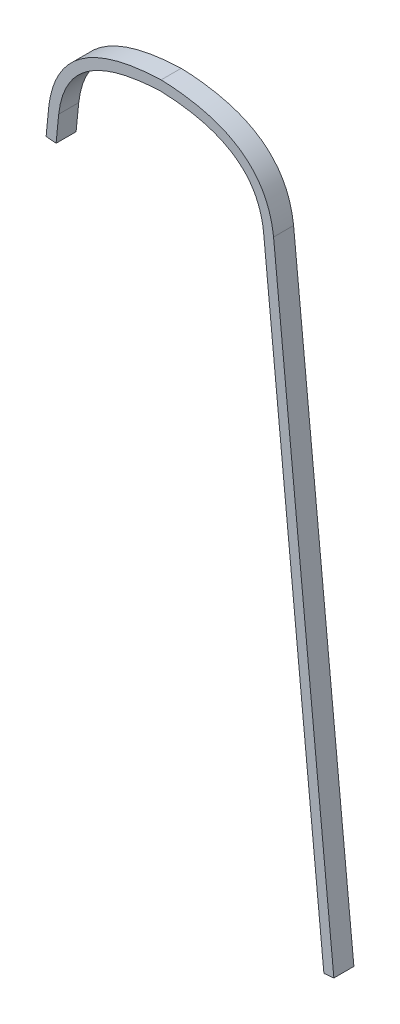
from build123d import *

# Parameters (mm, degrees)
BOSS_EXTRUDE1_DEPTH = 19.05


with BuildPart() as part:
    # Sketch1 → Boss-Extrude1 (new body)
    with BuildSketch(Plane.XY):
        with BuildLine():
            Line((154.716315659, 154.51789158), (97.403993572, 735.828587024))
            add(Edge.make_bspline(
                [(0, 803.26908628), (0.979817658, 803.233925105), (2.950075123, 803.151909058), (6.800362849, 802.946009068), (11.504912112, 802.608232022), (16.957304332, 802.075979486), (23.975792063, 801.198424891), (32.273128008, 799.790052384), (41.46699497, 797.614109593), (49.89784204, 794.967332344), (60.129456963, 790.832450746), (71.050790712, 784.572420078), (79.648241417, 776.932392043), (85.274313562, 769.943199813), (88.89525226, 764.228265264), (91.933130485, 758.00316425), (93.979934001, 752.359286407), (95.321414001, 747.554999291), (96.177362738, 743.805316844), (96.764020616, 740.553537606), (97.155379667, 737.881968465), (97.326205951, 736.51096636), (97.403993572, 735.828587024)],
                knots=[0.000508173, 0.000508173, 0.000508173, 0.000508173, 0.016098161, 0.031688149, 0.062868125, 0.094048101, 0.125228077, 0.187588029, 0.249947981, 0.312307933, 0.374667885, 0.499387789, 0.624107693, 0.686467645, 0.748827597, 0.811187549, 0.873547501, 0.904727477, 0.935907453, 0.967087429, 0.982677417, 0.998267405, 0.998267405, 0.998267405, 0.998267405], degree=3))
            add(Edge.make_bspline(
                [(-97.403993572, 735.828587024), (-97.326205951, 736.51096636), (-97.155379667, 737.881968465), (-96.764020616, 740.553537606), (-96.177362738, 743.805316844), (-95.321414001, 747.554999291), (-93.979934001, 752.359286407), (-91.933130485, 758.00316425), (-88.89525226, 764.228265264), (-85.274313562, 769.943199813), (-79.648241417, 776.932392043), (-71.050790712, 784.572420078), (-60.129456963, 790.832450746), (-49.89784204, 794.967332344), (-41.46699497, 797.614109593), (-32.273128008, 799.790052384), (-23.975792063, 801.198424891), (-16.957304332, 802.075979486), (-11.504912112, 802.608232022), (-6.800362849, 802.946009068), (-2.950075123, 803.151909058), (-0.979817658, 803.233925105), (0, 803.26908628)],
                knots=[0.000508173, 0.000508173, 0.000508173, 0.000508173, 0.016098161, 0.031688149, 0.062868125, 0.094048101, 0.125228077, 0.187588029, 0.249947981, 0.312307933, 0.374667885, 0.499387789, 0.624107693, 0.686467645, 0.748827597, 0.811187549, 0.873547501, 0.904727477, 0.935907453, 0.967087429, 0.982677417, 0.998267405, 0.998267405, 0.998267405, 0.998267405], degree=3))
            Line((-97.403993572, 735.828587024), (-99.889181424, 710.621681669))
            Line((-99.889181424, 710.621681669), (-109.368223301, 711.556235093))
            Line((-109.368223301, 711.556235093), (-106.876080835, 736.833680097))
            add(Edge.make_bspline(
                [(-106.876080835, 736.833680097), (-98.655564568, 809.385111394), (0, 812.8)],
                knots=[0, 0, 0, 1, 1, 1], degree=2))
            add(Edge.make_bspline(
                [(106.876080835, 736.833680097), (98.655564568, 809.385111394), (0, 812.8)],
                knots=[0, 0, 0, 1, 1, 1], degree=2))
            Line((106.876080835, 736.833680097), (164.195357535, 155.452445004))
            Line((164.195357535, 155.452445004), (154.716315659, 154.51789158))
        make_face()
    extrude(amount=BOSS_EXTRUDE1_DEPTH)


solid = part.part
